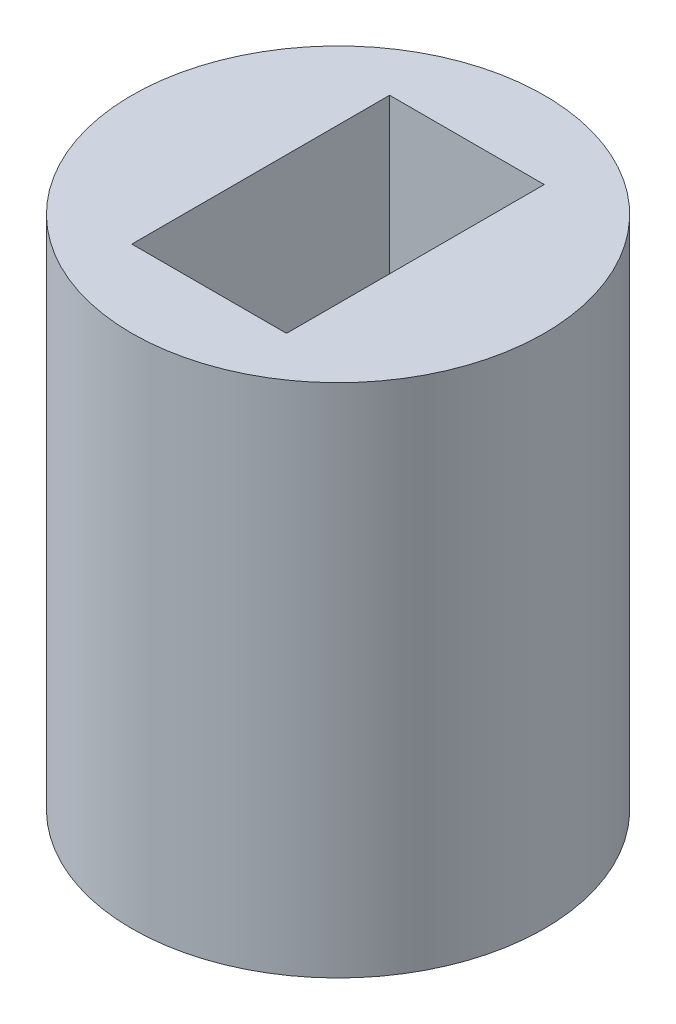
from build123d import *

# Parameters (mm, degrees)
SKETCH1_R           = 4
SKETCH1_W           = 3
SKETCH1_H           = 5
BOSS_EXTRUDE1_DEPTH = 10


with BuildPart() as part:
    # Sketch1 → Boss-Extrude1 (new body)
    with BuildSketch(Plane(origin=(0, 0, 0), x_dir=(1, 0, 0), z_dir=(0, 1, 0))):
        Circle(SKETCH1_R)
        Rectangle(SKETCH1_W, SKETCH1_H, mode=Mode.SUBTRACT)
    extrude(amount=BOSS_EXTRUDE1_DEPTH)


solid = part.part
